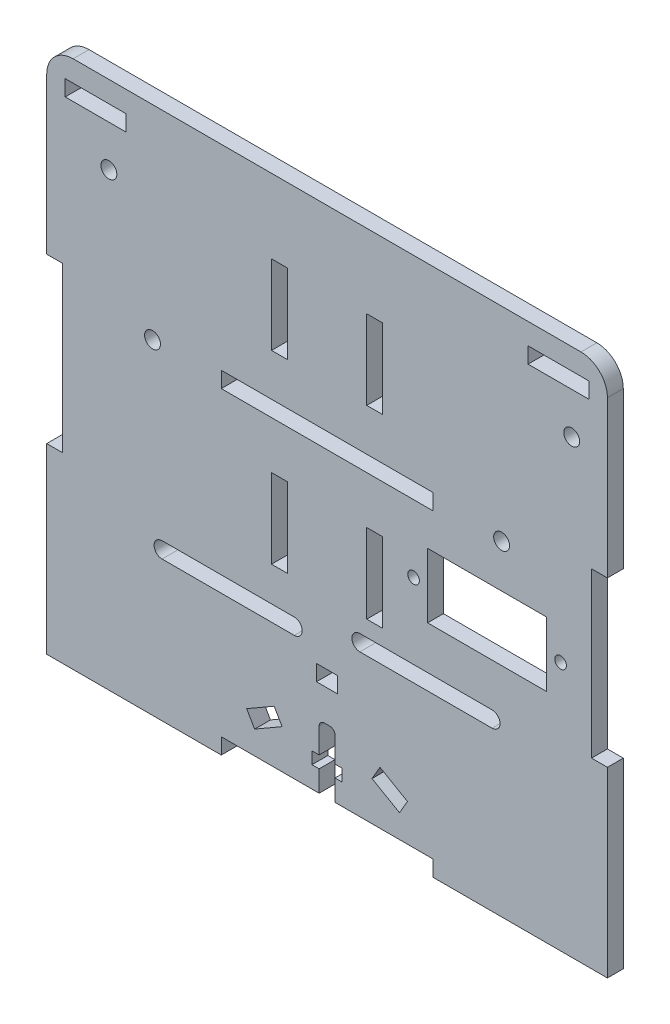
from build123d import *

# Parameters (mm, degrees)
ESBO_O1_W                 = 100
ESBO_O1_H                 = 100
RESSALTO_EXTRUS_O1_DEPTH  = 1.5
ESBO_O2_R                 = 1.5
ESBO_O2_W                 = 40
ESBO_O2_H                 = 3
CORTE_EXTRUS_O1_DEPTH     = 4
ESBO_O3_W                 = 3
ESBO_O3_H                 = 34.5
RESSALTO_EXTRUS_O2_DEPTH  = 3
CUT_EXTRUDE4_DEPTH        = 2.5
CUT_EXTRUDE4_DEPTH_BACK   = 2.5
FILLET1_R                 = 5
SKETCH3_W                 = 3
SKETCH3_H                 = 15
SKETCH3_W_2               = 4
SKETCH3_H_2               = 3
CUT_EXTRUDE5_DEPTH        = 2.5
CUT_EXTRUDE5_DEPTH_BACK   = 2.5
SKETCH8_R                 = 1.5
SKETCH8_W                 = 11.5
SKETCH8_H                 = 3
CORTE_GY_53LDK_DEPTH      = 2.5
CORTE_GY_53LDK_DEPTH_BACK = 2.5
SKETCH4_R                 = 1.1
SKETCH4_W                 = 22.5
SKETCH4_H                 = 12.2
CUT_EXTRUDE6_DEPTH        = 1
CUT_EXTRUDE6_DEPTH_BACK   = 4
CUT_EXTRUDE7_DEPTH        = 1
CUT_EXTRUDE7_DEPTH_BACK   = 4


with BuildPart() as part:
    # Esboço1 → Ressalto-extrusão1 (new body, symmetric)
    with BuildSketch(Plane.XY):
        Rectangle(ESBO_O1_W, ESBO_O1_H)
    extrude(amount=RESSALTO_EXTRUS_O1_DEPTH, both=True)

    # Esboço2 → Corte-extrusão1 (cut, through all)
    with BuildSketch(Plane.XY.offset(1.5)):
        with Locations((-33, 11.5)):
            Circle(ESBO_O2_R)
        with Locations((33, 11.5)):
            Circle(ESBO_O2_R)
        with Locations((0, -48.5)):
            Rectangle(ESBO_O2_W, ESBO_O2_H)
        with Locations((0, 11.5)):
            Rectangle(ESBO_O2_W, ESBO_O2_H)
    extrude(amount=-CORTE_EXTRUS_O1_DEPTH, mode=Mode.SUBTRACT)

    # Esboço3 → Ressalto-extrusão2 (add, through all)
    with BuildSketch(Plane.XY.offset(1.5)):
        with Locations((-51.5, -32.75)):
            Rectangle(ESBO_O3_W, ESBO_O3_H)
        with Locations((51.5, -32.75)):
            Rectangle(ESBO_O3_W, ESBO_O3_H)
        with Locations((-51.5, 32.75)):
            Rectangle(ESBO_O3_W, ESBO_O3_H)
        with Locations((51.5, 32.75)):
            Rectangle(ESBO_O3_W, ESBO_O3_H)
    extrude(amount=-RESSALTO_EXTRUS_O2_DEPTH)

    # Sketch2 → Cut-Extrude4 (cut, two sides)
    with BuildSketch(Plane.XY) as cut_extrude4_sk:
        with BuildLine():
            Line((-0.5, -35), (0.5, -35))
            ThreePointArc((0.5, -35), (1.207106781, -35.292893219), (1.5, -36))
            Line((1.5, -36), (1.5, -40.73))
            Line((1.5, -40.73), (2.85, -40.73))
            Line((2.85, -40.73), (2.85, -43))
            Line((2.85, -43), (1.5, -43))
            Line((1.5, -43), (1.5, -47))
            Line((1.5, -47), (-1.5, -47))
            Line((-1.5, -47), (-1.5, -43))
            Line((-1.5, -43), (-2.85, -43))
            Line((-2.85, -43), (-2.85, -40.73))
            Line((-2.85, -40.73), (-1.5, -40.73))
            Line((-1.5, -40.73), (-1.5, -36))
            ThreePointArc((-1.5, -36), (-1.207106781, -35.292893219), (-0.5, -35))
        make_face()
    extrude(amount=CUT_EXTRUDE4_DEPTH, mode=Mode.SUBTRACT)
    extrude(cut_extrude4_sk.sketch, amount=-CUT_EXTRUDE4_DEPTH_BACK, mode=Mode.SUBTRACT)

    # Fillet1
    fillet1_edges = [part.edges().sort_by_distance(p)[0] for p in [
        (53, 50, 0),
        (-53, 50, 0),
    ]]
    fillet(fillet1_edges, radius=FILLET1_R)

    # Sketch3 → Cut-Extrude5 (cut, two sides)
    with BuildSketch(Plane.XY) as cut_extrude5_sk:
        with Locations((9, -6.5)):
            Rectangle(SKETCH3_W, SKETCH3_H)
        with Locations((9, 28.5)):
            Rectangle(SKETCH3_W, SKETCH3_H)
        with Locations((-9, 28.5)):
            Rectangle(SKETCH3_W, SKETCH3_H)
        with Locations((-9, -6.5)):
            Rectangle(SKETCH3_W, SKETCH3_H)
        with Locations((0, -27.5)):
            Rectangle(SKETCH3_W_2, SKETCH3_H_2)
        Polygon((-15.196152423, -40), (-10, -37), (-8.5, -39.598076211), (-13.696152423, -42.598076211), align=None)
        Polygon((10, -37), (8.5, -39.598076211), (13.696152423, -42.598076211), (15.196152423, -40), align=None)
    extrude(amount=CUT_EXTRUDE5_DEPTH, mode=Mode.SUBTRACT)
    extrude(cut_extrude5_sk.sketch, amount=-CUT_EXTRUDE5_DEPTH_BACK, mode=Mode.SUBTRACT)

    # Sketch8 → Corte GY-53LDK (cut, two sides)
    with BuildSketch(Plane.XY) as corte_gy_53ldk_sk:
        with Locations((-41.25, 35.2)):
            Circle(SKETCH8_R)
        with Locations((46.25, 35.2)):
            Circle(SKETCH8_R)
        with Locations((-43.75, 44.5)):
            Rectangle(SKETCH8_W, SKETCH8_H)
        with Locations((43.75, 44.5)):
            Rectangle(SKETCH8_W, SKETCH8_H)
    extrude(amount=CORTE_GY_53LDK_DEPTH, mode=Mode.SUBTRACT)
    extrude(corte_gy_53ldk_sk.sketch, amount=-CORTE_GY_53LDK_DEPTH_BACK, mode=Mode.SUBTRACT)

    # Sketch4 → Cut-Extrude6 (cut, two sides)
    with BuildSketch(Plane.XY.offset(1.5)) as cut_extrude6_sk:
        with Locations((44.15, -2.75)):
            Circle(SKETCH4_R)
        with Locations((16.35, -2.75)):
            Circle(SKETCH4_R)
        with Locations((30.25, -2.75)):
            Rectangle(SKETCH4_W, SKETCH4_H)
    extrude(amount=CUT_EXTRUDE6_DEPTH, mode=Mode.SUBTRACT)
    extrude(cut_extrude6_sk.sketch, amount=-CUT_EXTRUDE6_DEPTH_BACK, mode=Mode.SUBTRACT)

    # Sketch6 → Cut-Extrude7 (cut, two sides)
    with BuildSketch(Plane.XY.offset(1.5)) as cut_extrude7_sk:
        with BuildLine():
            Line((-31.2, -20.5), (-6.2, -20.5))
            ThreePointArc((-6.2, -20.5), (-4.7, -22), (-6.2, -23.5))
            Line((-6.2, -23.5), (-31.2, -23.5))
            ThreePointArc((-31.2, -23.5), (-32.7, -22), (-31.2, -20.5))
        make_face()
        with BuildLine():
            Line((6.2, -17), (31.2, -17))
            ThreePointArc((31.2, -17), (32.7, -18.5), (31.2, -20))
            Line((31.2, -20), (6.2, -20))
            ThreePointArc((6.2, -20), (4.7, -18.5), (6.2, -17))
        make_face()
    extrude(amount=CUT_EXTRUDE7_DEPTH, mode=Mode.SUBTRACT)
    extrude(cut_extrude7_sk.sketch, amount=-CUT_EXTRUDE7_DEPTH_BACK, mode=Mode.SUBTRACT)


solid = part.part
